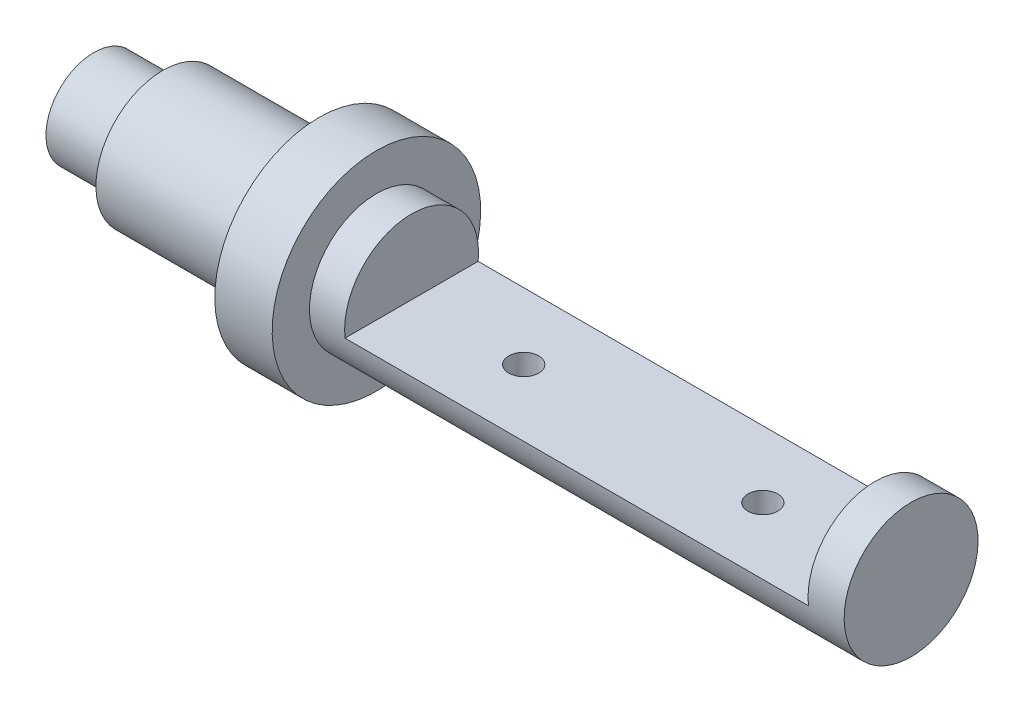
from build123d import *

# Parameters (mm, degrees)
SKETCH1_W               = 24
SKETCH1_H               = 15.6
SKETCH2_W               = 193.8
SKETCH2_H               = 31.1
CUT_EXTRUDE1_DEPTH      = 44.6
CUT_EXTRUDE1_DEPTH_BACK = 44.6
HOLE1_D                 = 12.5
HOLE1_DEPTH             = 24.9


with BuildPart() as part:
    # Sketch1 → Revolve2 (revolve)
    with BuildSketch(Plane.XY):
        Polygon((0, 20), (0, 0), (341.8, 0), (341.8, 28), (118.2, 28), (94.2, 28), (28.9, 28), (28.9, 20), align=None)
        with Locations((106.2, 35.8)):
            Rectangle(SKETCH1_W, SKETCH1_H)
    revolve(axis=Axis((341.8, 0, 0), (-1, 0, 0)))

    # Sketch2 → Cut-Extrude1 (cut, two sides)
    with BuildSketch(Plane.XY) as cut_extrude1_sk:
        with Locations((229.8, 12.45)):
            Rectangle(SKETCH2_W, SKETCH2_H)
    extrude(amount=CUT_EXTRUDE1_DEPTH, mode=Mode.SUBTRACT)
    extrude(cut_extrude1_sk.sketch, amount=-CUT_EXTRUDE1_DEPTH_BACK, mode=Mode.SUBTRACT)

    # Hole1
    with Locations(Plane(origin=(0, -3.1, 0), x_dir=(1, 0, 0), z_dir=(0, 1, 0))):
        with Locations((179.8, 0), (279.8, 0)):
            Hole(HOLE1_D / 2, depth=HOLE1_DEPTH)


solid = part.part
